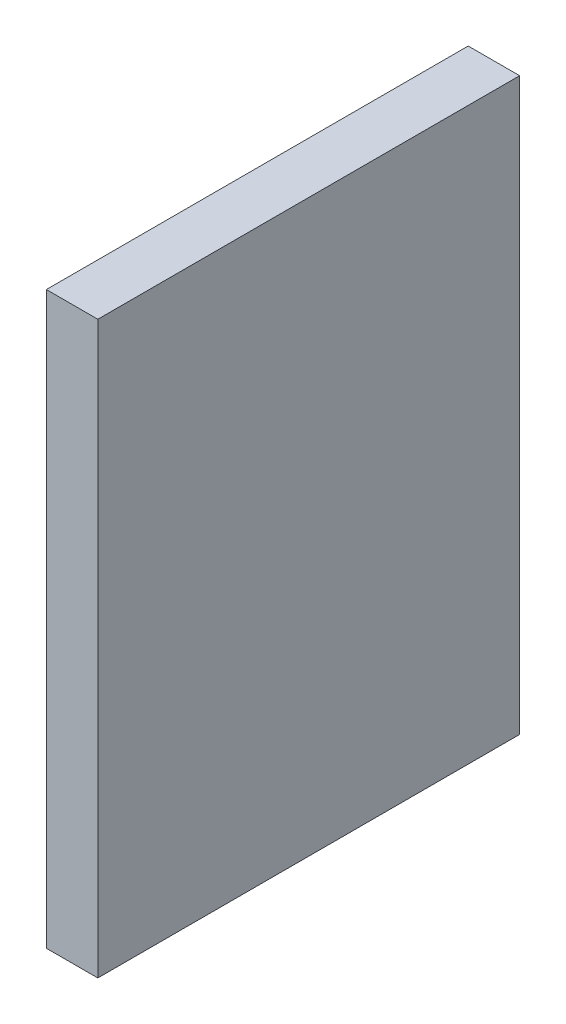
from build123d import *

# Parameters (mm, degrees)
CROQUIS1_W              = 24.6
CROQUIS1_H              = 33.270240546
SALIENTE_EXTRUIR1_DEPTH = 3


with BuildPart() as part:
    # Croquis1 → Saliente-Extruir1 (new body)
    with BuildSketch(Plane(origin=(0, 0, 0), x_dir=(0, 0, -1), z_dir=(1, 0, 0))):
        with Locations((-13.390515549, -4.772857027)):
            Rectangle(CROQUIS1_W, CROQUIS1_H)
    extrude(amount=SALIENTE_EXTRUIR1_DEPTH)


solid = part.part
